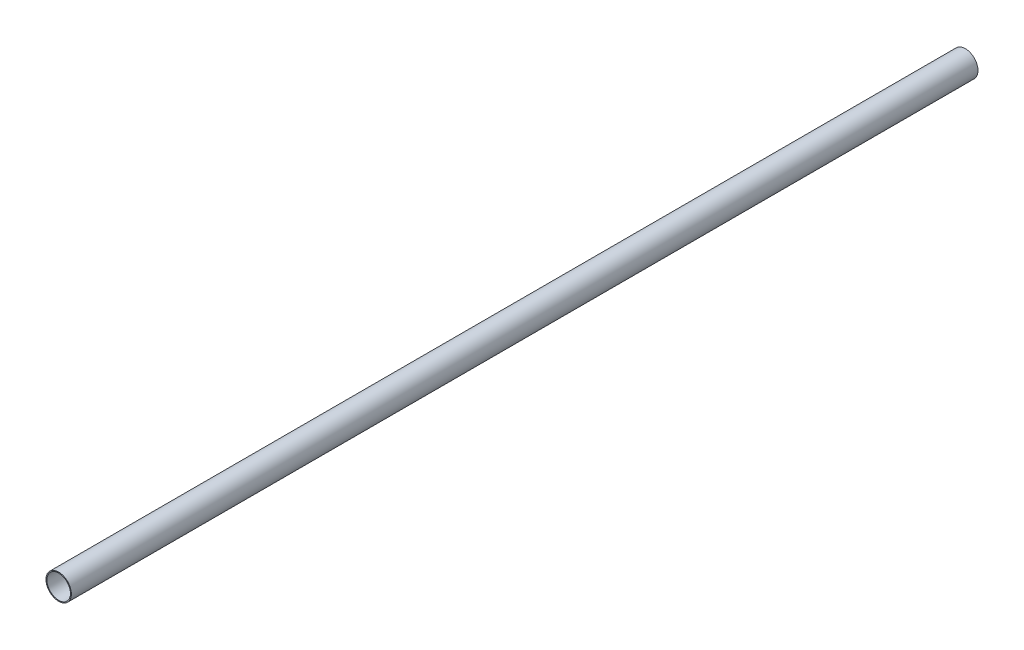
from build123d import *

# Parameters (mm, degrees)
SKETCH1_R           = 14
SKETCH1_R_2         = 13
BOSS_EXTRUDE1_DEPTH = 1000


with BuildPart() as part:
    # Sketch1 → Boss-Extrude1 (new body)
    with BuildSketch(Plane.XY):
        Circle(SKETCH1_R)
        Circle(SKETCH1_R_2, mode=Mode.SUBTRACT)
    extrude(amount=-BOSS_EXTRUDE1_DEPTH)


solid = part.part
